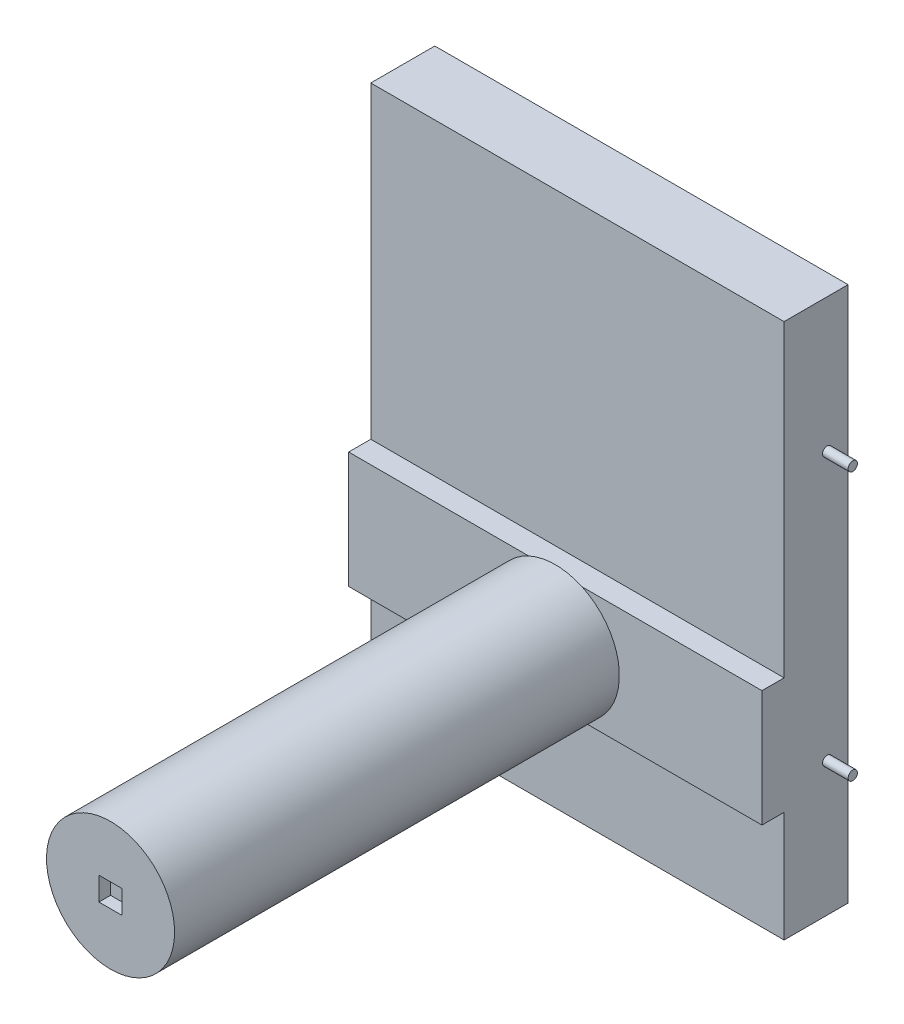
from build123d import *

# Parameters (mm, degrees)
BOSS_EXTRUDE1_DEPTH = 354.999989271
SKETCH2_R           = 4
BOSS_EXTRUDE2_DEPTH = 22
SKETCH3_R           = 4
BOSS_EXTRUDE3_DEPTH = 22
BOSS_EXTRUDE4_START = 22
SKETCH4_R           = 4
BOSS_EXTRUDE4_DEPTH = 22
BOSS_EXTRUDE5_START = 22
SKETCH5_R           = 4
BOSS_EXTRUDE5_DEPTH = 22
SKETCH6_R           = 55
BOSS_EXTRUDE6_DEPTH = 382
SKETCH8_W           = 20
SKETCH8_H           = 50
CUT_EXTRUDE1_DEPTH  = 10
MOVE_FACE1_BY       = 15
MOVE_FACE1_2_BY     = 15


with BuildPart() as part:
    # Sketch1 → Boss-Extrude1 (new body)
    with BuildSketch(Plane(origin=(354.999989271, 0, 0), x_dir=(0, 0, -1), z_dir=(1, 0, 0))):
        Polygon((-32.00000152, 460.000008345), (-86.999997497, 460.000008345), (-86.999997497, 194.999992847), (-105.999998748, 194.999992847), (-105.999998748, 94.999998808), (-86.999997497, 94.999998808), (-86.999997497, 0), (-32.00000152, 0), align=None)
    extrude(amount=-BOSS_EXTRUDE1_DEPTH)

    # Sketch2 → Boss-Extrude2 (add)
    with BuildSketch(Plane(origin=(354.999989271, 0, 0), x_dir=(0, 0, -1), z_dir=(1, 0, 0))):
        with Locations((-50.00000152, 345.000008345)):
            Circle(SKETCH2_R)
    extrude(amount=BOSS_EXTRUDE2_DEPTH)

    # Sketch3 → Boss-Extrude3 (add)
    with BuildSketch(Plane(origin=(354.999989271, 0, 0), x_dir=(0, 0, -1), z_dir=(1, 0, 0))):
        with Locations((-50.00000152, 115)):
            Circle(SKETCH3_R)
    extrude(amount=BOSS_EXTRUDE3_DEPTH)

    # Sketch4 → Boss-Extrude4 (add)
    with BuildSketch(Plane.ZY.offset(BOSS_EXTRUDE4_START)):
        with Locations((50.00000152, 115)):
            Circle(SKETCH4_R)
    extrude(amount=-BOSS_EXTRUDE4_DEPTH)

    # Sketch5 → Boss-Extrude5 (add)
    with BuildSketch(Plane.ZY.offset(BOSS_EXTRUDE5_START)):
        with Locations((50.00000152, 345.000008345)):
            Circle(SKETCH5_R)
    extrude(amount=-BOSS_EXTRUDE5_DEPTH)

    # Sketch6 → Boss-Extrude6 (add)
    with BuildSketch(Plane.XY.offset(105.999998748)):
        with Locations((177.5, 144.999998808)):
            Circle(SKETCH6_R)
    extrude(amount=BOSS_EXTRUDE6_DEPTH)

    # Sketch8 → Cut-Extrude1 (cut)
    with BuildSketch(Plane.XY.offset(487.999998748)):
        with Locations((177.5, 144.999998808)):
            Rectangle(SKETCH8_W, SKETCH8_H)
    extrude(amount=-CUT_EXTRUDE1_DEPTH, mode=Mode.SUBTRACT)

    # Move Face1: a face moved outward by 15.0
    extrude(part.faces().sort_by_distance((177.5, 169.999998808, 482.999998748))[0], amount=MOVE_FACE1_BY, dir=(0, -1, 0))

    # Move Face1 2: a face moved outward by 15.0
    extrude(part.faces().sort_by_distance((177.5, 119.999998808, 482.999998748))[0], amount=MOVE_FACE1_2_BY, dir=(0, 1, 0))


solid = part.part
